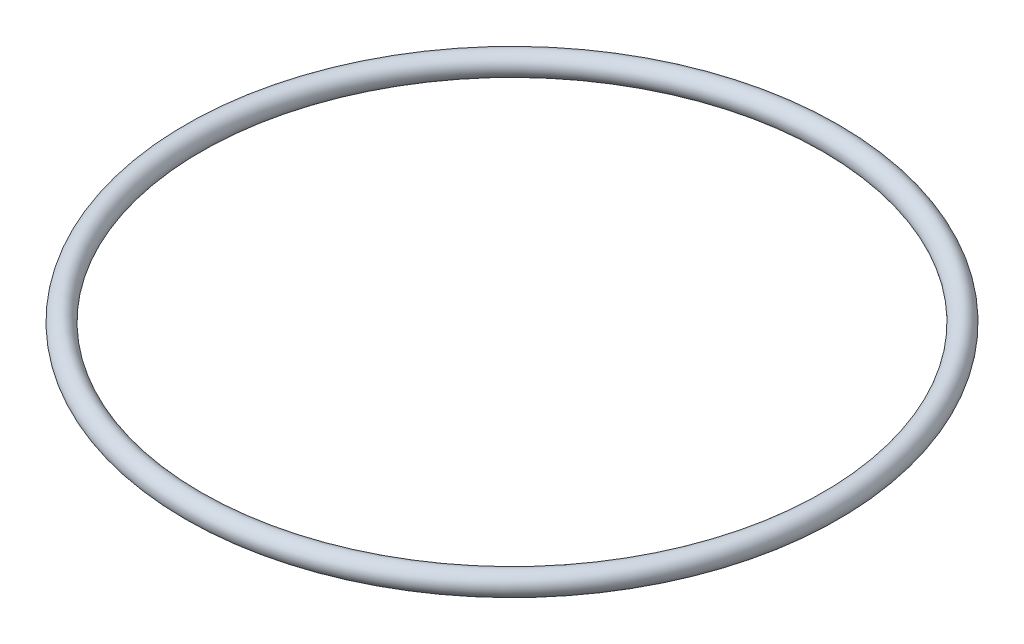
from build123d import *

# Parameters (mm, degrees)
SKETCH1_R = 1


with BuildPart() as part:
    # Sketch1 → Revolve1 (revolve)
    with BuildSketch(Plane.XY):
        with Locations((-29, 0)):
            Circle(SKETCH1_R)
    revolve(axis=Axis((0, 0, 0), (0, 1, 0)))


solid = part.part
